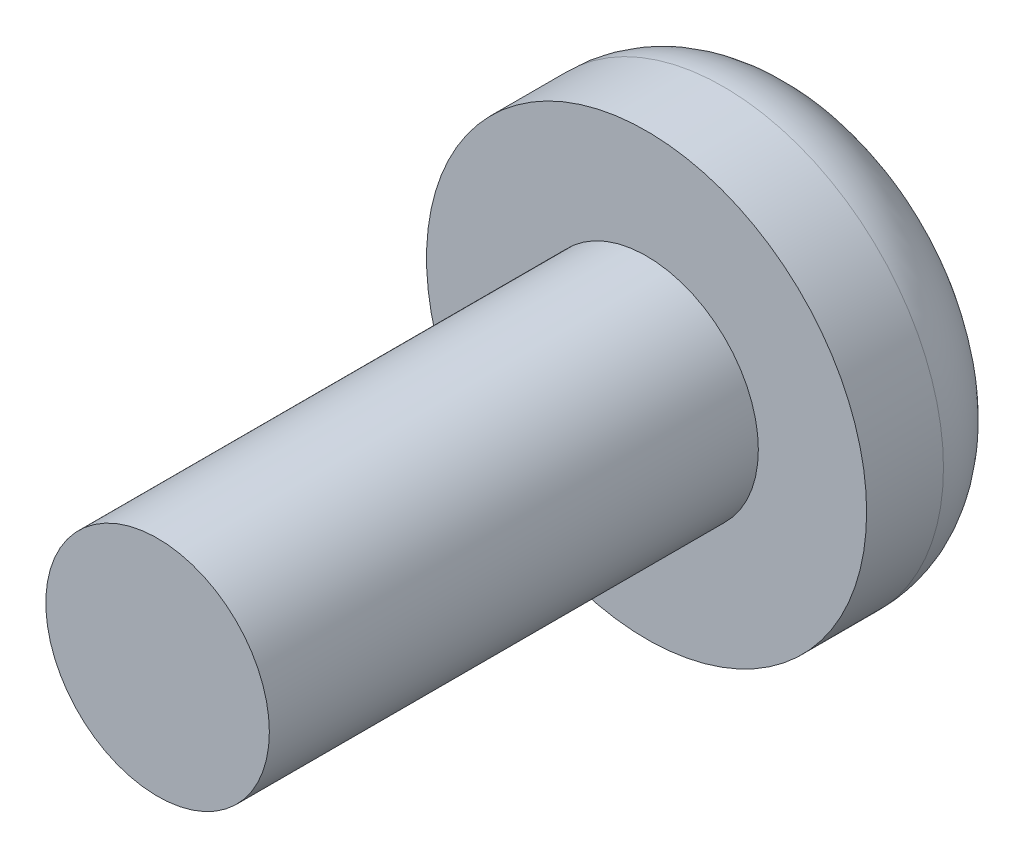
from build123d import *

# Parameters (mm, degrees)
SKETCH1_R         = 4.0005
EXTRUDE1_DEPTH    = 2.921
FILLET1_R         = 1.524
SKETCH2_R         = 2.032
EXTRUDE2_DEPTH    = 8.89
SKETCH3_W         = 4.91456988
SKETCH3_H         = 0.615801824
EXTRUDE3_DEPTH    = 1.016
CIRPATTERN1_COUNT = 2
CIRPATTERN1_ANGLE = 90


with BuildPart() as part:
    # Sketch1 → Extrude1 (new body)
    with BuildSketch(Plane.XY):
        Circle(SKETCH1_R)
    extrude(amount=EXTRUDE1_DEPTH)

    # Fillet1
    fillet1_edges = [part.edges().sort_by_distance(p)[0] for p in [
        (-4.0005, 0, 0),
    ]]
    fillet(fillet1_edges, radius=FILLET1_R)

    # Sketch2 → Extrude2 (add)
    with BuildSketch(Plane.XY.offset(2.921)):
        Circle(SKETCH2_R)
    extrude(amount=EXTRUDE2_DEPTH)

    # Sketch3 → Extrude3 (cut)
    with BuildSketch(Plane(origin=(0, 0, 0), x_dir=(-1, 0, 0), z_dir=(0, 0, -1))):
        Rectangle(SKETCH3_W, SKETCH3_H)
    extrude3 = extrude(amount=-EXTRUDE3_DEPTH, mode=Mode.SUBTRACT)

    # CirPattern1: Extrude3 ×2 about axis
    cirpattern1_axis = Axis((0, 0, 0), (0, 0, -1))
    for i in range(1, CIRPATTERN1_COUNT):
        add(extrude3.rotate(cirpattern1_axis, i * CIRPATTERN1_ANGLE / (CIRPATTERN1_COUNT - 1)), mode=Mode.SUBTRACT)


solid = part.part
